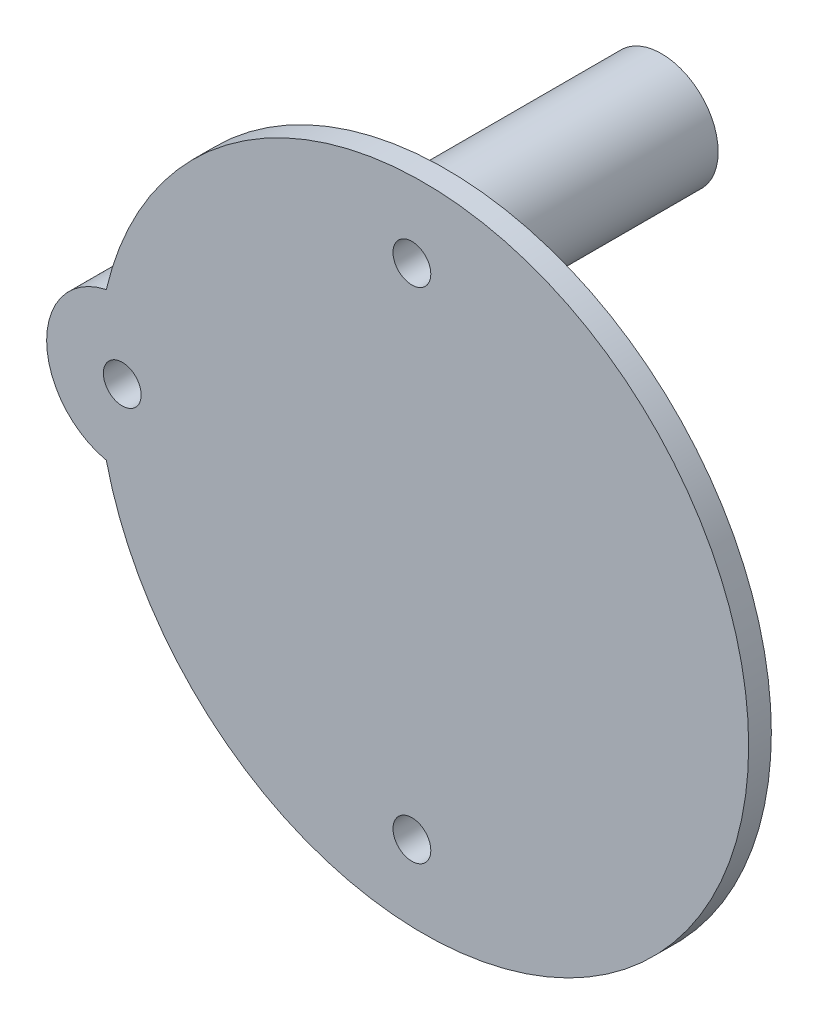
from build123d import *

# Parameters (mm, degrees)
SKETCH1_R             = 7.5
SKETCH1_R_2           = 5
BOSS_EXTRUDE1_DEPTH   = 3
SKETCH1_R_3           = 10
BOSS_EXTRUDE1_2_DEPTH = 3
SKETCH1_R_4           = 7
BOSS_EXTRUDE1_3_DEPTH = 3
SKETCH3_R             = 7
SKETCH3_R_2           = 7.5
SKETCH3_R_3           = 10
BOSS_EXTRUDE2_DEPTH   = 27
BOSS_EXTRUDE3_DEPTH   = 3
SKETCH5_R             = 2.5
CUT_EXTRUDE1_DEPTH    = 34


with BuildPart() as part:
    # Sketch1 → Boss-Extrude1 (new body)
    with BuildSketch(Plane.XY):
        with Locations((29, 78)):
            Circle(SKETCH1_R)
        with Locations((29, 78)):
            Circle(SKETCH1_R_2, mode=Mode.SUBTRACT)
    extrude(amount=BOSS_EXTRUDE1_DEPTH)



with BuildPart() as body_2:
    # Sketch1 → Boss-Extrude1 2 (new body)
    with BuildSketch(Plane.XY):
        with Locations((-9.3, 45)):
            Circle(SKETCH1_R_3)
        with Locations((-9.3, 45)):
            Circle(SKETCH1_R_2, mode=Mode.SUBTRACT)
    extrude(amount=BOSS_EXTRUDE1_2_DEPTH)


with BuildPart() as body_3:
    # Sketch1 → Boss-Extrude1 3 (new body)
    with BuildSketch(Plane.XY):
        with Locations((29, 12)):
            Circle(SKETCH1_R_4)
        with Locations((29, 12)):
            Circle(SKETCH1_R_2, mode=Mode.SUBTRACT)
    extrude(amount=BOSS_EXTRUDE1_3_DEPTH)


with BuildPart() as part_1:
    add(part.part)

    add(body_2.part)  # Boss-Extrude2 merges body 2

    add(body_3.part)  # Boss-Extrude2 merges body 3
    # Sketch3 → Boss-Extrude2 (add)
    with BuildSketch(Plane.XY.offset(3)):
        with Locations((29, 12)):
            Circle(SKETCH3_R)
        with Locations((29, 78)):
            Circle(SKETCH3_R_2)
        with Locations((-9.3, 45)):
            Circle(SKETCH3_R_3)
    extrude(amount=BOSS_EXTRUDE2_DEPTH)

    # Sketch4 → Boss-Extrude3 (add)
    with BuildSketch(Plane.XY.offset(30)):
        with BuildLine():
            ThreePointArc((-11.409189276, 35.22496442), (73.534073318, 45), (-11.409189276, 54.77503558))
            ThreePointArc((-11.409189276, 54.77503558), (-19.3, 45), (-11.409189276, 35.22496442))
        make_face()
    extrude(amount=BOSS_EXTRUDE3_DEPTH)

    # Sketch5 → Cut-Extrude1 (cut, through all)
    with BuildSketch(Plane.XY.offset(33)):
        with Locations((-9.3, 45)):
            Circle(SKETCH5_R)
        with Locations((29, 12)):
            Circle(SKETCH5_R)
        with Locations((29, 78)):
            Circle(SKETCH5_R)
    extrude(amount=-CUT_EXTRUDE1_DEPTH, mode=Mode.SUBTRACT)


solid = part_1.part
